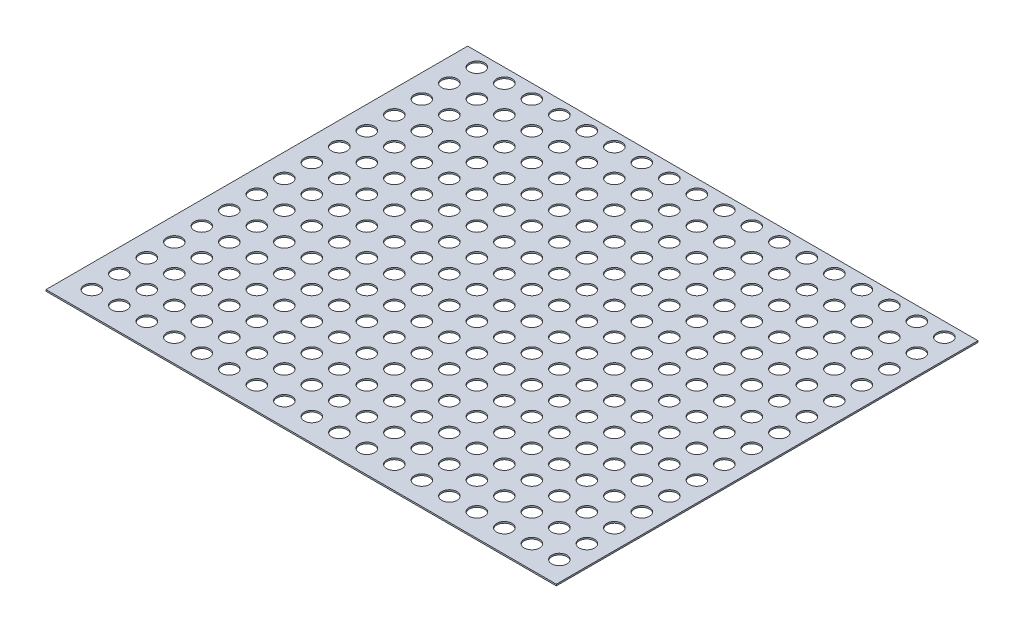
from build123d import *

# Parameters (mm, degrees)
SKETCH_1_W               = 334
SKETCH_1_H               = 276
EXTRUDE_1_DEPTH          = 1
SKETCH_2_R               = 5
CUT_EXTRUDE_1_DEPTH      = 1
CUT_EXTRUDE_1_DEPTH_BACK = 2


with BuildPart() as part:
    # Эскиз1 → Бобышка-Вытянуть1 (new body)
    with BuildSketch(Plane(origin=(0, 0, 0), x_dir=(1, 0, 0), z_dir=(0, 1, 0))):
        Rectangle(SKETCH_1_W, SKETCH_1_H)
    extrude(amount=EXTRUDE_1_DEPTH)

    # Эскиз2 → Вырез-Вытянуть1 (cut, two sides)
    with BuildSketch(Plane(origin=(0, 1, 0), x_dir=(1, 0, 0), z_dir=(0, 1, 0))) as cut_extrude_1_sk:
        with Locations((-152, -123)):
            Circle(SKETCH_2_R)
        with Locations((-134, -123)):
            Circle(SKETCH_2_R)
        with Locations((-116, -123)):
            Circle(SKETCH_2_R)
        with Locations((-98, -123)):
            Circle(SKETCH_2_R)
        with Locations((-80, -123)):
            Circle(SKETCH_2_R)
        with Locations((-62, -123)):
            Circle(SKETCH_2_R)
        with Locations((-44, -123)):
            Circle(SKETCH_2_R)
        with Locations((-26, -123)):
            Circle(SKETCH_2_R)
        with Locations((-8, -123)):
            Circle(SKETCH_2_R)
        with Locations((10, -123)):
            Circle(SKETCH_2_R)
        with Locations((28, -123)):
            Circle(SKETCH_2_R)
        with Locations((46, -123)):
            Circle(SKETCH_2_R)
        with Locations((64, -123)):
            Circle(SKETCH_2_R)
        with Locations((82, -123)):
            Circle(SKETCH_2_R)
        with Locations((100, -123)):
            Circle(SKETCH_2_R)
        with Locations((118, -123)):
            Circle(SKETCH_2_R)
        with Locations((136, -123)):
            Circle(SKETCH_2_R)
        with Locations((154, -123)):
            Circle(SKETCH_2_R)
        with Locations((-134, -105)):
            Circle(SKETCH_2_R)
        with Locations((-116, -105)):
            Circle(SKETCH_2_R)
        with Locations((-98, -105)):
            Circle(SKETCH_2_R)
        with Locations((-80, -105)):
            Circle(SKETCH_2_R)
        with Locations((-62, -105)):
            Circle(SKETCH_2_R)
        with Locations((-44, -105)):
            Circle(SKETCH_2_R)
        with Locations((-26, -105)):
            Circle(SKETCH_2_R)
        with Locations((-8, -105)):
            Circle(SKETCH_2_R)
        with Locations((10, -105)):
            Circle(SKETCH_2_R)
        with Locations((28, -105)):
            Circle(SKETCH_2_R)
        with Locations((46, -105)):
            Circle(SKETCH_2_R)
        with Locations((64, -105)):
            Circle(SKETCH_2_R)
        with Locations((82, -105)):
            Circle(SKETCH_2_R)
        with Locations((100, -105)):
            Circle(SKETCH_2_R)
        with Locations((118, -105)):
            Circle(SKETCH_2_R)
        with Locations((136, -105)):
            Circle(SKETCH_2_R)
        with Locations((154, -105)):
            Circle(SKETCH_2_R)
        with Locations((-134, -87)):
            Circle(SKETCH_2_R)
        with Locations((-116, -87)):
            Circle(SKETCH_2_R)
        with Locations((-98, -87)):
            Circle(SKETCH_2_R)
        with Locations((-80, -87)):
            Circle(SKETCH_2_R)
        with Locations((-62, -87)):
            Circle(SKETCH_2_R)
        with Locations((-44, -87)):
            Circle(SKETCH_2_R)
        with Locations((-26, -87)):
            Circle(SKETCH_2_R)
        with Locations((-8, -87)):
            Circle(SKETCH_2_R)
        with Locations((10, -87)):
            Circle(SKETCH_2_R)
        with Locations((28, -87)):
            Circle(SKETCH_2_R)
        with Locations((46, -87)):
            Circle(SKETCH_2_R)
        with Locations((64, -87)):
            Circle(SKETCH_2_R)
        with Locations((82, -87)):
            Circle(SKETCH_2_R)
        with Locations((100, -87)):
            Circle(SKETCH_2_R)
        with Locations((118, -87)):
            Circle(SKETCH_2_R)
        with Locations((136, -87)):
            Circle(SKETCH_2_R)
        with Locations((154, -87)):
            Circle(SKETCH_2_R)
        with Locations((-134, -69)):
            Circle(SKETCH_2_R)
        with Locations((-116, -69)):
            Circle(SKETCH_2_R)
        with Locations((-98, -69)):
            Circle(SKETCH_2_R)
        with Locations((-80, -69)):
            Circle(SKETCH_2_R)
        with Locations((-62, -69)):
            Circle(SKETCH_2_R)
        with Locations((-44, -69)):
            Circle(SKETCH_2_R)
        with Locations((-26, -69)):
            Circle(SKETCH_2_R)
        with Locations((-8, -69)):
            Circle(SKETCH_2_R)
        with Locations((10, -69)):
            Circle(SKETCH_2_R)
        with Locations((28, -69)):
            Circle(SKETCH_2_R)
        with Locations((46, -69)):
            Circle(SKETCH_2_R)
        with Locations((64, -69)):
            Circle(SKETCH_2_R)
        with Locations((82, -69)):
            Circle(SKETCH_2_R)
        with Locations((100, -69)):
            Circle(SKETCH_2_R)
        with Locations((118, -69)):
            Circle(SKETCH_2_R)
        with Locations((136, -69)):
            Circle(SKETCH_2_R)
        with Locations((154, -69)):
            Circle(SKETCH_2_R)
        with Locations((-134, -51)):
            Circle(SKETCH_2_R)
        with Locations((-116, -51)):
            Circle(SKETCH_2_R)
        with Locations((-98, -51)):
            Circle(SKETCH_2_R)
        with Locations((-80, -51)):
            Circle(SKETCH_2_R)
        with Locations((-62, -51)):
            Circle(SKETCH_2_R)
        with Locations((-44, -51)):
            Circle(SKETCH_2_R)
        with Locations((-26, -51)):
            Circle(SKETCH_2_R)
        with Locations((-8, -51)):
            Circle(SKETCH_2_R)
        with Locations((10, -51)):
            Circle(SKETCH_2_R)
        with Locations((28, -51)):
            Circle(SKETCH_2_R)
        with Locations((46, -51)):
            Circle(SKETCH_2_R)
        with Locations((64, -51)):
            Circle(SKETCH_2_R)
        with Locations((82, -51)):
            Circle(SKETCH_2_R)
        with Locations((100, -51)):
            Circle(SKETCH_2_R)
        with Locations((118, -51)):
            Circle(SKETCH_2_R)
        with Locations((136, -51)):
            Circle(SKETCH_2_R)
        with Locations((154, -51)):
            Circle(SKETCH_2_R)
        with Locations((-134, -33)):
            Circle(SKETCH_2_R)
        with Locations((-116, -33)):
            Circle(SKETCH_2_R)
        with Locations((-98, -33)):
            Circle(SKETCH_2_R)
        with Locations((-80, -33)):
            Circle(SKETCH_2_R)
        with Locations((-62, -33)):
            Circle(SKETCH_2_R)
        with Locations((-44, -33)):
            Circle(SKETCH_2_R)
        with Locations((-26, -33)):
            Circle(SKETCH_2_R)
        with Locations((-8, -33)):
            Circle(SKETCH_2_R)
        with Locations((10, -33)):
            Circle(SKETCH_2_R)
        with Locations((28, -33)):
            Circle(SKETCH_2_R)
        with Locations((46, -33)):
            Circle(SKETCH_2_R)
        with Locations((64, -33)):
            Circle(SKETCH_2_R)
        with Locations((82, -33)):
            Circle(SKETCH_2_R)
        with Locations((100, -33)):
            Circle(SKETCH_2_R)
        with Locations((118, -33)):
            Circle(SKETCH_2_R)
        with Locations((136, -33)):
            Circle(SKETCH_2_R)
        with Locations((154, -33)):
            Circle(SKETCH_2_R)
        with Locations((-134, -15)):
            Circle(SKETCH_2_R)
        with Locations((-116, -15)):
            Circle(SKETCH_2_R)
        with Locations((-98, -15)):
            Circle(SKETCH_2_R)
        with Locations((-80, -15)):
            Circle(SKETCH_2_R)
        with Locations((-62, -15)):
            Circle(SKETCH_2_R)
        with Locations((-44, -15)):
            Circle(SKETCH_2_R)
        with Locations((-26, -15)):
            Circle(SKETCH_2_R)
        with Locations((-8, -15)):
            Circle(SKETCH_2_R)
        with Locations((10, -15)):
            Circle(SKETCH_2_R)
        with Locations((28, -15)):
            Circle(SKETCH_2_R)
        with Locations((46, -15)):
            Circle(SKETCH_2_R)
        with Locations((64, -15)):
            Circle(SKETCH_2_R)
        with Locations((82, -15)):
            Circle(SKETCH_2_R)
        with Locations((100, -15)):
            Circle(SKETCH_2_R)
        with Locations((118, -15)):
            Circle(SKETCH_2_R)
        with Locations((136, -15)):
            Circle(SKETCH_2_R)
        with Locations((154, -15)):
            Circle(SKETCH_2_R)
        with Locations((-134, 3)):
            Circle(SKETCH_2_R)
        with Locations((-116, 3)):
            Circle(SKETCH_2_R)
        with Locations((-98, 3)):
            Circle(SKETCH_2_R)
        with Locations((-80, 3)):
            Circle(SKETCH_2_R)
        with Locations((-62, 3)):
            Circle(SKETCH_2_R)
        with Locations((-44, 3)):
            Circle(SKETCH_2_R)
        with Locations((-26, 3)):
            Circle(SKETCH_2_R)
        with Locations((-8, 3)):
            Circle(SKETCH_2_R)
        with Locations((10, 3)):
            Circle(SKETCH_2_R)
        with Locations((28, 3)):
            Circle(SKETCH_2_R)
        with Locations((46, 3)):
            Circle(SKETCH_2_R)
        with Locations((64, 3)):
            Circle(SKETCH_2_R)
        with Locations((82, 3)):
            Circle(SKETCH_2_R)
        with Locations((100, 3)):
            Circle(SKETCH_2_R)
        with Locations((118, 3)):
            Circle(SKETCH_2_R)
        with Locations((136, 3)):
            Circle(SKETCH_2_R)
        with Locations((154, 3)):
            Circle(SKETCH_2_R)
        with Locations((-134, 21)):
            Circle(SKETCH_2_R)
        with Locations((-116, 21)):
            Circle(SKETCH_2_R)
        with Locations((-98, 21)):
            Circle(SKETCH_2_R)
        with Locations((-80, 21)):
            Circle(SKETCH_2_R)
        with Locations((-62, 21)):
            Circle(SKETCH_2_R)
        with Locations((-44, 21)):
            Circle(SKETCH_2_R)
        with Locations((-26, 21)):
            Circle(SKETCH_2_R)
        with Locations((-8, 21)):
            Circle(SKETCH_2_R)
        with Locations((10, 21)):
            Circle(SKETCH_2_R)
        with Locations((28, 21)):
            Circle(SKETCH_2_R)
        with Locations((46, 21)):
            Circle(SKETCH_2_R)
        with Locations((64, 21)):
            Circle(SKETCH_2_R)
        with Locations((82, 21)):
            Circle(SKETCH_2_R)
        with Locations((100, 21)):
            Circle(SKETCH_2_R)
        with Locations((118, 21)):
            Circle(SKETCH_2_R)
        with Locations((136, 21)):
            Circle(SKETCH_2_R)
        with Locations((154, 21)):
            Circle(SKETCH_2_R)
        with Locations((-134, 39)):
            Circle(SKETCH_2_R)
        with Locations((-116, 39)):
            Circle(SKETCH_2_R)
        with Locations((-98, 39)):
            Circle(SKETCH_2_R)
        with Locations((-80, 39)):
            Circle(SKETCH_2_R)
        with Locations((-62, 39)):
            Circle(SKETCH_2_R)
        with Locations((-44, 39)):
            Circle(SKETCH_2_R)
        with Locations((-26, 39)):
            Circle(SKETCH_2_R)
        with Locations((-8, 39)):
            Circle(SKETCH_2_R)
        with Locations((10, 39)):
            Circle(SKETCH_2_R)
        with Locations((28, 39)):
            Circle(SKETCH_2_R)
        with Locations((46, 39)):
            Circle(SKETCH_2_R)
        with Locations((64, 39)):
            Circle(SKETCH_2_R)
        with Locations((82, 39)):
            Circle(SKETCH_2_R)
        with Locations((100, 39)):
            Circle(SKETCH_2_R)
        with Locations((118, 39)):
            Circle(SKETCH_2_R)
        with Locations((136, 39)):
            Circle(SKETCH_2_R)
        with Locations((154, 39)):
            Circle(SKETCH_2_R)
        with Locations((-134, 57)):
            Circle(SKETCH_2_R)
        with Locations((-116, 57)):
            Circle(SKETCH_2_R)
        with Locations((-98, 57)):
            Circle(SKETCH_2_R)
        with Locations((-80, 57)):
            Circle(SKETCH_2_R)
        with Locations((-62, 57)):
            Circle(SKETCH_2_R)
        with Locations((-44, 57)):
            Circle(SKETCH_2_R)
        with Locations((-26, 57)):
            Circle(SKETCH_2_R)
        with Locations((-8, 57)):
            Circle(SKETCH_2_R)
        with Locations((10, 57)):
            Circle(SKETCH_2_R)
        with Locations((28, 57)):
            Circle(SKETCH_2_R)
        with Locations((46, 57)):
            Circle(SKETCH_2_R)
        with Locations((64, 57)):
            Circle(SKETCH_2_R)
        with Locations((82, 57)):
            Circle(SKETCH_2_R)
        with Locations((100, 57)):
            Circle(SKETCH_2_R)
        with Locations((118, 57)):
            Circle(SKETCH_2_R)
        with Locations((136, 57)):
            Circle(SKETCH_2_R)
        with Locations((154, 57)):
            Circle(SKETCH_2_R)
        with Locations((-134, 75)):
            Circle(SKETCH_2_R)
        with Locations((-116, 75)):
            Circle(SKETCH_2_R)
        with Locations((-98, 75)):
            Circle(SKETCH_2_R)
        with Locations((-80, 75)):
            Circle(SKETCH_2_R)
        with Locations((-62, 75)):
            Circle(SKETCH_2_R)
        with Locations((-44, 75)):
            Circle(SKETCH_2_R)
        with Locations((-26, 75)):
            Circle(SKETCH_2_R)
        with Locations((-8, 75)):
            Circle(SKETCH_2_R)
        with Locations((10, 75)):
            Circle(SKETCH_2_R)
        with Locations((28, 75)):
            Circle(SKETCH_2_R)
        with Locations((46, 75)):
            Circle(SKETCH_2_R)
        with Locations((64, 75)):
            Circle(SKETCH_2_R)
        with Locations((82, 75)):
            Circle(SKETCH_2_R)
        with Locations((100, 75)):
            Circle(SKETCH_2_R)
        with Locations((118, 75)):
            Circle(SKETCH_2_R)
        with Locations((136, 75)):
            Circle(SKETCH_2_R)
        with Locations((154, 75)):
            Circle(SKETCH_2_R)
        with Locations((-134, 93)):
            Circle(SKETCH_2_R)
        with Locations((-116, 93)):
            Circle(SKETCH_2_R)
        with Locations((-98, 93)):
            Circle(SKETCH_2_R)
        with Locations((-80, 93)):
            Circle(SKETCH_2_R)
        with Locations((-62, 93)):
            Circle(SKETCH_2_R)
        with Locations((-44, 93)):
            Circle(SKETCH_2_R)
        with Locations((-26, 93)):
            Circle(SKETCH_2_R)
        with Locations((-8, 93)):
            Circle(SKETCH_2_R)
        with Locations((10, 93)):
            Circle(SKETCH_2_R)
        with Locations((28, 93)):
            Circle(SKETCH_2_R)
        with Locations((46, 93)):
            Circle(SKETCH_2_R)
        with Locations((64, 93)):
            Circle(SKETCH_2_R)
        with Locations((82, 93)):
            Circle(SKETCH_2_R)
        with Locations((100, 93)):
            Circle(SKETCH_2_R)
        with Locations((118, 93)):
            Circle(SKETCH_2_R)
        with Locations((136, 93)):
            Circle(SKETCH_2_R)
        with Locations((154, 93)):
            Circle(SKETCH_2_R)
        with Locations((-134, 111)):
            Circle(SKETCH_2_R)
        with Locations((-116, 111)):
            Circle(SKETCH_2_R)
        with Locations((-98, 111)):
            Circle(SKETCH_2_R)
        with Locations((-80, 111)):
            Circle(SKETCH_2_R)
        with Locations((-62, 111)):
            Circle(SKETCH_2_R)
        with Locations((-44, 111)):
            Circle(SKETCH_2_R)
        with Locations((-26, 111)):
            Circle(SKETCH_2_R)
        with Locations((-8, 111)):
            Circle(SKETCH_2_R)
        with Locations((10, 111)):
            Circle(SKETCH_2_R)
        with Locations((28, 111)):
            Circle(SKETCH_2_R)
        with Locations((46, 111)):
            Circle(SKETCH_2_R)
        with Locations((64, 111)):
            Circle(SKETCH_2_R)
        with Locations((82, 111)):
            Circle(SKETCH_2_R)
        with Locations((100, 111)):
            Circle(SKETCH_2_R)
        with Locations((118, 111)):
            Circle(SKETCH_2_R)
        with Locations((136, 111)):
            Circle(SKETCH_2_R)
        with Locations((154, 111)):
            Circle(SKETCH_2_R)
        with Locations((-134, 129)):
            Circle(SKETCH_2_R)
        with Locations((-116, 129)):
            Circle(SKETCH_2_R)
        with Locations((-98, 129)):
            Circle(SKETCH_2_R)
        with Locations((-80, 129)):
            Circle(SKETCH_2_R)
        with Locations((-62, 129)):
            Circle(SKETCH_2_R)
        with Locations((-44, 129)):
            Circle(SKETCH_2_R)
        with Locations((-26, 129)):
            Circle(SKETCH_2_R)
        with Locations((-8, 129)):
            Circle(SKETCH_2_R)
        with Locations((10, 129)):
            Circle(SKETCH_2_R)
        with Locations((28, 129)):
            Circle(SKETCH_2_R)
        with Locations((46, 129)):
            Circle(SKETCH_2_R)
        with Locations((64, 129)):
            Circle(SKETCH_2_R)
        with Locations((82, 129)):
            Circle(SKETCH_2_R)
        with Locations((100, 129)):
            Circle(SKETCH_2_R)
        with Locations((118, 129)):
            Circle(SKETCH_2_R)
        with Locations((136, 129)):
            Circle(SKETCH_2_R)
        with Locations((154, 129)):
            Circle(SKETCH_2_R)
        with Locations((-152, -105)):
            Circle(SKETCH_2_R)
        with Locations((-152, -87)):
            Circle(SKETCH_2_R)
        with Locations((-152, -69)):
            Circle(SKETCH_2_R)
        with Locations((-152, -51)):
            Circle(SKETCH_2_R)
        with Locations((-152, -33)):
            Circle(SKETCH_2_R)
        with Locations((-152, -15)):
            Circle(SKETCH_2_R)
        with Locations((-152, 3)):
            Circle(SKETCH_2_R)
        with Locations((-152, 21)):
            Circle(SKETCH_2_R)
        with Locations((-152, 39)):
            Circle(SKETCH_2_R)
        with Locations((-152, 57)):
            Circle(SKETCH_2_R)
        with Locations((-152, 75)):
            Circle(SKETCH_2_R)
        with Locations((-152, 93)):
            Circle(SKETCH_2_R)
        with Locations((-152, 111)):
            Circle(SKETCH_2_R)
        with Locations((-152, 129)):
            Circle(SKETCH_2_R)
    extrude(amount=CUT_EXTRUDE_1_DEPTH, mode=Mode.SUBTRACT)
    extrude(cut_extrude_1_sk.sketch, amount=-CUT_EXTRUDE_1_DEPTH_BACK, mode=Mode.SUBTRACT)


solid = part.part
